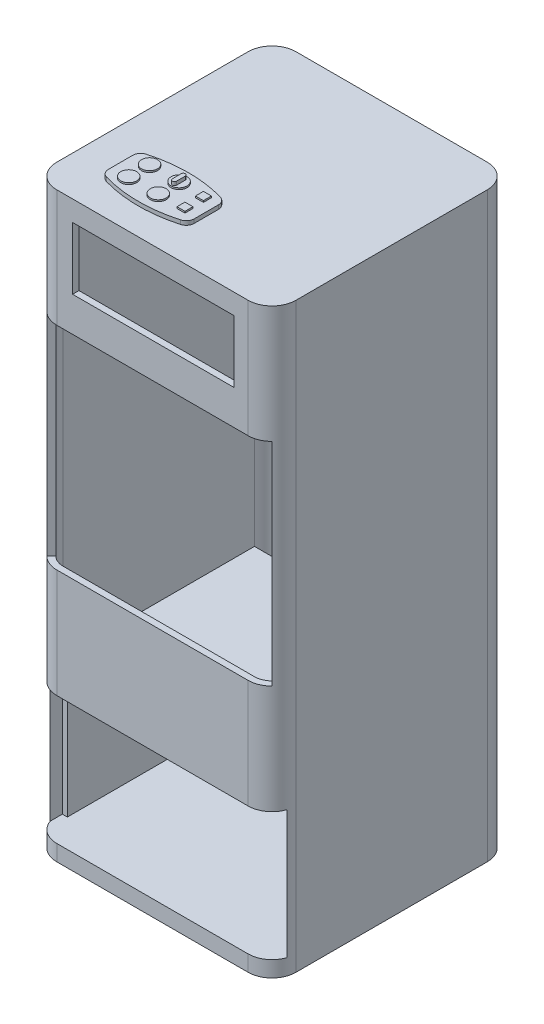
from build123d import *

# Parameters (mm, degrees)
SKETCH1_W            = 381
SKETCH1_H            = 381
BOSS_EXTRUDE1_DEPTH  = 25.4
BOSS_EXTRUDE2_DEPTH  = 6.35
SKETCH3_R            = 12.7
SKETCH3_W            = 12.7
SKETCH3_H            = 12.7
BOSS_EXTRUDE3_DEPTH  = 2.54
FILLET1_R            = 38.1
BOSS_EXTRUDE4_DEPTH  = 914.4
BOSS_EXTRUDE5_DEPTH  = 12.7
CUT_EXTRUDE2_DEPTH   = 167.894
SKETCH11_W           = 304.8
SKETCH11_H           = 337.560693512
CUT_EXTRUDE7_DEPTH   = 110.998
SKETCH14_W           = 376.723987394
SKETCH14_H           = 204.033096405
CUT_EXTRUDE9_DEPTH   = 672.066
BOSS_EXTRUDE7_DEPTH  = 12.7
BOSS_EXTRUDE8_REACH  = 372.84
SKETCH16_W           = 304.8
SKETCH16_H           = 6.578487437
SKETCH17_W           = 256.984779842
SKETCH17_H           = 99.117758391
CUT_EXTRUDE10_DEPTH  = 65.532
BOSS_EXTRUDE9_DEPTH  = 337.560694
BOSS_EXTRUDE10_DEPTH = 5.588


with BuildPart() as part:
    # Sketch1 → Boss-Extrude1 (new body)
    with BuildSketch(Plane(origin=(0, 0, 0), x_dir=(1, 0, 0), z_dir=(0, 1, 0))):
        with Locations((-145.071527203, 145.702478214)):
            Rectangle(SKETCH1_W, SKETCH1_H)
    extrude(amount=BOSS_EXTRUDE1_DEPTH)

    # Sketch2 → Boss-Extrude2 (add)
    with BuildSketch(Plane(origin=(0, 25.4, 0), x_dir=(1, 0, 0), z_dir=(0, 1, 0))):
        with BuildLine():
            Line((-278.18981895, 56.909871518), (-278.18981895, 18.239718765))
            ThreePointArc((-278.18981895, 18.239718765), (-275.624301912, 10.585814199), (-268.964266966, 6.024228149))
            ThreePointArc((-268.964266966, 6.024228149), (-209.898650693, -2.212431383), (-150.833034421, 6.024228149))
            ThreePointArc((-150.833034421, 6.024228149), (-144.172999475, 10.585814199), (-141.607482437, 18.239718765))
            Line((-141.607482437, 18.239718765), (-141.607482437, 56.909871518))
            ThreePointArc((-141.607482437, 56.909871518), (-144.172999475, 64.563776083), (-150.833034421, 69.125362134))
            ThreePointArc((-150.833034421, 69.125362134), (-209.898650693, 77.362021666), (-268.964266966, 69.125362134))
            ThreePointArc((-268.964266966, 69.125362134), (-275.624301912, 64.563776083), (-278.18981895, 56.909871518))
        make_face()
    extrude(amount=BOSS_EXTRUDE2_DEPTH)

    # Sketch3 → Boss-Extrude3 (add)
    with BuildSketch(Plane(origin=(0, 31.75, 0), x_dir=(1, 0, 0), z_dir=(0, 1, 0))):
        with Locations((-249.948168026, 55.44519483)):
            Circle(SKETCH3_R)
        with Locations((-249.948168026, 22.311626762)):
            Circle(SKETCH3_R)
        with Locations((-202.863297366, 55.44519483)):
            Circle(SKETCH3_R)
        with Locations((-202.863297366, 22.311626762)):
            Circle(SKETCH3_R)
        with Locations((-163.252071019, 54.565913405)):
            Rectangle(SKETCH3_W, SKETCH3_H)
        with Locations((-163.138085387, 25.086983412)):
            Rectangle(SKETCH3_W, SKETCH3_H)
    extrude(amount=BOSS_EXTRUDE3_DEPTH)

    # Fillet1
    fillet1_edges = [part.edges().sort_by_distance(p)[0] for p in [
        (-335.571527203, 12.7, -336.202478214),
        (45.428472797, 12.7, -336.202478214),
        (45.428472797, 12.7, 44.797521786),
        (-335.571527203, 12.7, 44.797521786),
    ]]
    fillet(fillet1_edges, radius=FILLET1_R)

    # Sketch6 → Boss-Extrude4 (add)
    with BuildSketch(Plane(origin=(0, 25.4, 0), x_dir=(1, 0, 0), z_dir=(0, 1, 0))):
        with BuildLine():
            Line((-335.571527203, 298.102478214), (-335.571527203, -6.697521786))
            ThreePointArc((-335.571527203, -6.697521786), (-324.412295566, -33.638290149), (-297.471527203, -44.797521786))
            Line((-297.471527203, -44.797521786), (7.328472797, -44.797521786))
            ThreePointArc((7.328472797, -44.797521786), (34.26924116, -33.638290149), (45.428472797, -6.697521786))
            Line((45.428472797, -6.697521786), (45.428472797, 298.102478214))
            ThreePointArc((45.428472797, 298.102478214), (34.26924116, 325.043246577), (7.328472797, 336.202478214))
            Line((7.328472797, 336.202478214), (-297.471527203, 336.202478214))
            ThreePointArc((-297.471527203, 336.202478214), (-324.412295566, 325.043246577), (-335.571527203, 298.102478214))
        make_face()
        with BuildLine():
            Line((7.328472797, 326.042478214), (-297.471527203, 326.042478214))
            ThreePointArc((-297.471527203, 326.042478214), (-317.22809067, 317.859041681), (-325.411527203, 298.102478214))
            Line((-325.411527203, 298.102478214), (-325.411527203, -6.697521786))
            ThreePointArc((-325.411527203, -6.697521786), (-317.22809067, -26.454085252), (-297.471527203, -34.637521786))
            Line((-297.471527203, -34.637521786), (7.328472797, -34.637521786))
            ThreePointArc((7.328472797, -34.637521786), (27.085036263, -26.454085252), (35.268472797, -6.697521786))
            Line((35.268472797, -6.697521786), (35.268472797, 298.102478214))
            ThreePointArc((35.268472797, 298.102478214), (27.085036263, 317.859041681), (7.328472797, 326.042478214))
        make_face(mode=Mode.SUBTRACT)
    extrude(amount=-BOSS_EXTRUDE4_DEPTH)

    # Sketch7 → Boss-Extrude5 (add)
    with BuildSketch(Plane.XZ.offset(889)):
        with BuildLine():
            Line((-297.471527203, -336.202478214), (7.328472797, -336.202478214))
            ThreePointArc((7.328472797, -336.202478214), (34.26924116, -325.043246577), (45.428472797, -298.102478214))
            Line((45.428472797, -298.102478214), (45.428472797, 6.697521786))
            ThreePointArc((45.428472797, 6.697521786), (34.26924116, 33.638290149), (7.328472797, 44.797521786))
            Line((7.328472797, 44.797521786), (-297.471527203, 44.797521786))
            ThreePointArc((-297.471527203, 44.797521786), (-324.412295566, 33.638290149), (-335.571527203, 6.697521786))
            Line((-335.571527203, 6.697521786), (-335.571527203, -298.102478214))
            ThreePointArc((-335.571527203, -298.102478214), (-324.412295566, -325.043246577), (-297.471527203, -336.202478214))
        make_face()
    extrude(amount=BOSS_EXTRUDE5_DEPTH)

    # Sketch9 → Cut-Extrude2 (cut)
    with BuildSketch(Plane.XY):
        with BuildLine():
            Line((45.428472797, -161.419653244), (-335.571527203, -161.419653244))
            Line((-335.571527203, -161.419653244), (-259.140976729, -229.136056455))
            ThreePointArc((-259.140976729, -229.136056455), (-145.071527203, -177.8), (-31.002077677, -229.136056455))
            Line((-31.002077677, -229.136056455), (45.428472797, -161.419653244))
        make_face()
        with BuildLine():
            Line((-335.571527203, -161.419653244), (-335.571527203, -498.980346756))
            Line((-335.571527203, -498.980346756), (-259.140976729, -431.263943545))
            ThreePointArc((-259.140976729, -431.263943545), (-297.471527203, -330.2), (-259.140976729, -229.136056455))
            Line((-259.140976729, -229.136056455), (-335.571527203, -161.419653244))
        make_face()
        with BuildLine():
            Line((-31.002077677, -431.263943545), (45.428472797, -498.980346756))
            Line((45.428472797, -498.980346756), (45.428472797, -161.419653244))
            Line((45.428472797, -161.419653244), (-31.002077677, -229.136056455))
            ThreePointArc((-31.002077677, -229.136056455), (-2.576011295, -276.155685349), (7.328472797, -330.2))
            ThreePointArc((7.328472797, -330.2), (-2.576011295, -384.244314651), (-31.002077677, -431.263943545))
        make_face()
        with BuildLine():
            Line((-259.140976729, -431.263943545), (-335.571527203, -498.980346756))
            Line((-335.571527203, -498.980346756), (45.428472797, -498.980346756))
            Line((45.428472797, -498.980346756), (-31.002077677, -431.263943545))
            ThreePointArc((-31.002077677, -431.263943545), (-145.071527203, -482.6), (-259.140976729, -431.263943545))
        make_face()
        with BuildLine():
            ThreePointArc((-259.140976729, -229.136056455), (-297.471527203, -330.2), (-259.140976729, -431.263943545))
            Line((-259.140976729, -431.263943545), (-145.071527203, -330.2))
            Line((-145.071527203, -330.2), (-259.140976729, -229.136056455))
        make_face()
        with BuildLine():
            Line((-145.071527203, -330.2), (-259.140976729, -431.263943545))
            ThreePointArc((-259.140976729, -431.263943545), (-145.071527203, -482.6), (-31.002077677, -431.263943545))
            Line((-31.002077677, -431.263943545), (-145.071527203, -330.2))
        make_face()
        with BuildLine():
            Line((-145.071527203, -330.2), (-31.002077677, -431.263943545))
            ThreePointArc((-31.002077677, -431.263943545), (-2.576011295, -384.244314651), (7.328472797, -330.2))
            ThreePointArc((7.328472797, -330.2), (-2.576011295, -276.155685349), (-31.002077677, -229.136056455))
            Line((-31.002077677, -229.136056455), (-145.071527203, -330.2))
        make_face()
        with BuildLine():
            ThreePointArc((-31.002077677, -229.136056455), (-145.071527203, -177.8), (-259.140976729, -229.136056455))
            Line((-259.140976729, -229.136056455), (-145.071527203, -330.2))
            Line((-145.071527203, -330.2), (-31.002077677, -229.136056455))
        make_face()
    extrude(amount=CUT_EXTRUDE2_DEPTH, mode=Mode.SUBTRACT)

    # Sketch11 → Cut-Extrude7 (cut)
    with BuildSketch(Plane(origin=(0, 0, -336.202478214), x_dir=(-1, 0, 0), z_dir=(0, 0, -1))):
        with Locations((145.071527203, -330.2)):
            Rectangle(SKETCH11_W, SKETCH11_H)
    extrude(amount=-CUT_EXTRUDE7_DEPTH, mode=Mode.SUBTRACT)

    # Sketch14 → Cut-Extrude9 (cut)
    with BuildSketch(Plane.XY):
        with Locations((-145.03055799, -774.283451797)):
            Rectangle(SKETCH14_W, SKETCH14_H)
    extrude(amount=CUT_EXTRUDE9_DEPTH, mode=Mode.SUBTRACT)

    # Sketch15 → Boss-Extrude7 (add)
    with BuildSketch(Plane(origin=(0, -889, 0), x_dir=(1, 0, 0), z_dir=(0, 1, 0))):
        with BuildLine():
            Line((35.268472797, -6.697521786), (35.268472797, 298.102478214))
            ThreePointArc((35.268472797, 298.102478214), (27.085036263, 317.859041681), (7.328472797, 326.042478214))
            Line((7.328472797, 326.042478214), (-297.471527203, 326.042478214))
            ThreePointArc((-297.471527203, 326.042478214), (-317.22809067, 317.859041681), (-325.411527203, 298.102478214))
            Line((-325.411527203, 298.102478214), (-325.411527203, -6.697521786))
            ThreePointArc((-325.411527203, -6.697521786), (-317.22809067, -26.454085252), (-297.471527203, -34.637521786))
            Line((-297.471527203, -34.637521786), (7.328472797, -34.637521786))
            ThreePointArc((7.328472797, -34.637521786), (27.085036263, -26.454085252), (35.268472797, -6.697521786))
        make_face()
    extrude(amount=BOSS_EXTRUDE7_DEPTH)

    # Sketch16 → Boss-Extrude8 (add, up to next)
    with BuildSketch(Plane(origin=(-325.411527203, 0, 0), x_dir=(0, 0, -1), z_dir=(1, 0, 0)), mode=Mode.PRIVATE) as boss_extrude8_sk1:
        with Locations((145.702478214, -655.281036831)):
            Rectangle(SKETCH16_W, SKETCH16_H)
    boss_extrude8_tool1 = extrude(boss_extrude8_sk1.sketch, amount=BOSS_EXTRUDE8_REACH, mode=Mode.PRIVATE) - part.part
    add(boss_extrude8_tool1.solids().sort_by_distance((-325.411527, -655.281037, -145.702478))[0])

    # Sketch17 → Cut-Extrude10 (cut)
    with BuildSketch(Plane.XY.offset(44.797521786)):
        with Locations((-143.832555223, -56.589097106)):
            Rectangle(SKETCH17_W, SKETCH17_H)
    extrude(amount=-CUT_EXTRUDE10_DEPTH, mode=Mode.SUBTRACT)

    # Sketch18 → Boss-Extrude9 (add)
    with BuildSketch(Plane(origin=(0, -498.980346756, 0), x_dir=(1, 0, 0), z_dir=(0, 1, 0))):
        with BuildLine():
            ThreePointArc((-335.571527203, -6.697521786), (-332.671337392, -21.277760559), (-324.412295566, -33.638290149))
            Line((-324.412295566, -33.638290149), (-317.22809067, -26.454085252))
            ThreePointArc((-317.22809067, -26.454085252), (-323.284721342, -17.389696886), (-325.411527203, -6.697521786))
            Line((-325.411527203, -6.697521786), (-325.411527203, 0))
            Line((-325.411527203, 0), (-335.571527203, 0))
            Line((-335.571527203, 0), (-335.571527203, -6.697521786))
        make_face()
        with BuildLine():
            Line((27.085036263, -26.454085252), (34.26924116, -33.638290149))
            ThreePointArc((34.26924116, -33.638290149), (42.528282985, -21.277760559), (45.428472797, -6.697521786))
            Line((45.428472797, -6.697521786), (45.428472797, 0))
            Line((45.428472797, 0), (35.268472797, 0))
            Line((35.268472797, 0), (35.268472797, -6.697521786))
            ThreePointArc((35.268472797, -6.697521786), (33.141666935, -17.389696886), (27.085036263, -26.454085252))
        make_face()
    extrude(amount=BOSS_EXTRUDE9_DEPTH)

    # Sketch19 → Boss-Extrude10 (add)
    with BuildSketch(Plane(origin=(0, 34.29, 0), x_dir=(1, 0, 0), z_dir=(0, 1, 0))):
        with BuildLine():
            Line((-199.52514655, 61.981140549), (-199.52514655, 47.926597628))
            ThreePointArc((-199.52514655, 47.926597628), (-202.811044116, 44.640700062), (-206.096941682, 47.926597628))
            Line((-206.096941682, 47.926597628), (-206.096941682, 61.981140549))
            ThreePointArc((-206.096941682, 61.981140549), (-202.811044116, 65.267038115), (-199.52514655, 61.981140549))
        make_face()
    extrude(amount=BOSS_EXTRUDE10_DEPTH)


solid = part.part
